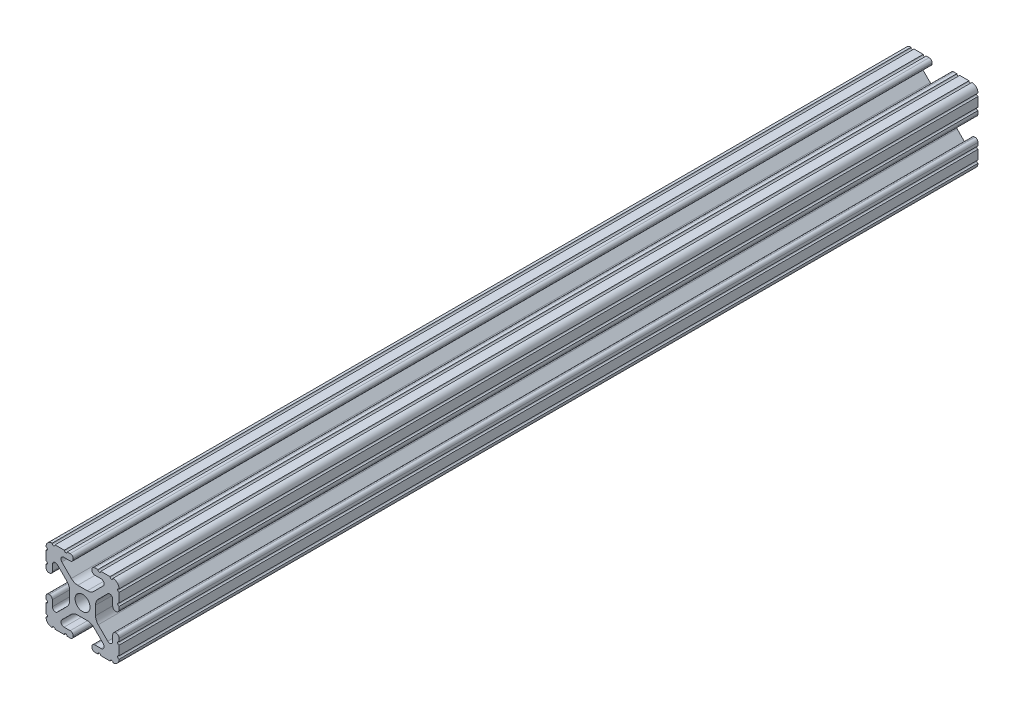
from build123d import *

# Parameters (mm, degrees)
SKETCH1_R           = 2.6035
BOSS_EXTRUDE1_DEPTH = 149.225


with BuildPart() as part:
    # Sketch1 → Boss-Extrude1 (new body, symmetric)
    with BuildSketch(Plane.XY):
        with BuildLine():
            Line((-7.179650497, -8.645192506), (-3.952270251, -5.423690499))
            ThreePointArc((-3.952270251, -5.423690499), (-2.922936451, -4.736929036), (-1.709253557, -4.4958))
            Line((-1.709253557, -4.4958), (1.709253557, -4.4958))
            ThreePointArc((1.709253557, -4.4958), (2.922936451, -4.736929036), (3.952270251, -5.423690499))
            Line((3.952270251, -5.423690499), (7.179650497, -8.645192506))
            ThreePointArc((7.179650497, -8.645192506), (7.41473083, -9.822813117), (6.416408329, -10.4902))
            Line((6.416408329, -10.4902), (4.287512407, -10.4902))
            ThreePointArc((4.287512407, -10.4902), (3.54574862, -10.79744862), (3.2385, -11.539212407))
            Line((3.2385, -11.539212407), (3.2385, -11.650987593))
            ThreePointArc((3.2385, -11.650987593), (3.54574862, -12.39275138), (4.287512407, -12.7))
            Line((4.287512407, -12.7), (5.317126718, -12.7))
            ThreePointArc((5.317126718, -12.7), (5.825126718, -12.192), (6.333126718, -12.7))
            Line((6.333126718, -12.7), (9.550443118, -12.7))
            ThreePointArc((9.550443118, -12.7), (10.058366869, -12.192000006), (10.566443095, -12.699847501))
            ThreePointArc((10.566443095, -12.699847501), (12.082537762, -12.08250727), (12.699846982, -10.566399977))
            ThreePointArc((12.699846982, -10.566399977), (12.192000006, -10.058323491), (12.7, -9.5504))
            Line((12.7, -9.5504), (12.7, -6.3330836))
            ThreePointArc((12.7, -6.3330836), (12.192, -5.8250836), (12.7, -5.3170836))
            Line((12.7, -5.3170836), (12.7, -4.287469289))
            ThreePointArc((12.7, -4.287469289), (12.39275138, -3.545705502), (11.650987593, -3.238456882))
            Line((11.650987593, -3.238456882), (11.539212407, -3.238456882))
            ThreePointArc((11.539212407, -3.238456882), (10.79744862, -3.545705502), (10.4902, -4.287469289))
            Line((10.4902, -4.287469289), (10.4902, -6.402089023))
            ThreePointArc((10.4902, -6.402089023), (9.856505071, -7.351067942), (8.737131347, -7.129408934))
            Line((8.737131347, -7.129408934), (5.441005833, -3.840816462))
            ThreePointArc((5.441005833, -3.840816462), (4.750877967, -2.809883091), (4.5085, -1.593185507))
            Line((4.5085, -1.593185507), (4.5085, 1.593185507))
            ThreePointArc((4.5085, 1.593185507), (4.750877967, 2.809883091), (5.441005833, 3.840816462))
            Line((5.441005833, 3.840816462), (8.737131347, 7.129408934))
            ThreePointArc((8.737131347, 7.129408934), (9.856505071, 7.351067942), (10.4902, 6.402089023))
            Line((10.4902, 6.402089023), (10.4902, 4.287469289))
            ThreePointArc((10.4902, 4.287469289), (10.79744862, 3.545705502), (11.539212407, 3.238456882))
            Line((11.539212407, 3.238456882), (11.650987593, 3.238456882))
            ThreePointArc((11.650987593, 3.238456882), (12.39275138, 3.545705502), (12.7, 4.287469289))
            Line((12.7, 4.287469289), (12.7, 5.3170836))
            ThreePointArc((12.7, 5.3170836), (12.192, 5.8250836), (12.7, 6.3330836))
            Line((12.7, 6.3330836), (12.7, 9.5504))
            ThreePointArc((12.7, 9.5504), (12.192000006, 10.058323491), (12.699846982, 10.566399977))
            ThreePointArc((12.699846982, 10.566399977), (12.082537762, 12.08250727), (10.566443095, 12.699847501))
            ThreePointArc((10.566443095, 12.699847501), (10.058366869, 12.192000006), (9.550443118, 12.7))
            Line((9.550443118, 12.7), (6.333126718, 12.7))
            ThreePointArc((6.333126718, 12.7), (5.825126718, 12.192), (5.317126718, 12.7))
            Line((5.317126718, 12.7), (4.287512407, 12.7))
            ThreePointArc((4.287512407, 12.7), (3.54574862, 12.39275138), (3.2385, 11.650987593))
            Line((3.2385, 11.650987593), (3.2385, 11.539212407))
            ThreePointArc((3.2385, 11.539212407), (3.54574862, 10.79744862), (4.287512407, 10.4902))
            Line((4.287512407, 10.4902), (6.476788598, 10.4902))
            ThreePointArc((6.476788598, 10.4902), (7.432222385, 9.85140422), (7.207036008, 8.724370562))
            Line((7.207036008, 8.724370562), (3.898272566, 5.423169045))
            ThreePointArc((3.898272566, 5.423169045), (2.869120213, 4.736787962), (1.655778399, 4.4958))
            Line((1.655778399, 4.4958), (-1.655778399, 4.4958))
            ThreePointArc((-1.655778399, 4.4958), (-2.869120213, 4.736787962), (-3.898272566, 5.423169045))
            Line((-3.898272566, 5.423169045), (-7.207036008, 8.724370562))
            ThreePointArc((-7.207036008, 8.724370562), (-7.432222385, 9.85140422), (-6.476788598, 10.4902))
            Line((-6.476788598, 10.4902), (-4.287512407, 10.4902))
            ThreePointArc((-4.287512407, 10.4902), (-3.54574862, 10.79744862), (-3.2385, 11.539212407))
            Line((-3.2385, 11.539212407), (-3.2385, 11.650987593))
            ThreePointArc((-3.2385, 11.650987593), (-3.54574862, 12.39275138), (-4.287512407, 12.7))
            Line((-4.287512407, 12.7), (-5.317126718, 12.7))
            ThreePointArc((-5.317126718, 12.7), (-5.825126718, 12.192), (-6.333126718, 12.7))
            Line((-6.333126718, 12.7), (-9.550443118, 12.7))
            ThreePointArc((-9.550443118, 12.7), (-10.058366869, 12.192000006), (-10.566443095, 12.699847501))
            ThreePointArc((-10.566443095, 12.699847501), (-12.082537762, 12.08250727), (-12.699846982, 10.566399977))
            ThreePointArc((-12.699846982, 10.566399977), (-12.192000006, 10.058323491), (-12.7, 9.5504))
            Line((-12.7, 9.5504), (-12.7, 6.3330836))
            ThreePointArc((-12.7, 6.3330836), (-12.192, 5.8250836), (-12.7, 5.3170836))
            Line((-12.7, 5.3170836), (-12.7, 4.287469289))
            ThreePointArc((-12.7, 4.287469289), (-12.39275138, 3.545705502), (-11.650987593, 3.238456882))
            Line((-11.650987593, 3.238456882), (-11.539212407, 3.238456882))
            ThreePointArc((-11.539212407, 3.238456882), (-10.79744862, 3.545705502), (-10.4902, 4.287469289))
            Line((-10.4902, 4.287469289), (-10.4902, 6.402089023))
            ThreePointArc((-10.4902, 6.402089023), (-9.856505071, 7.351067942), (-8.737131347, 7.129408934))
            Line((-8.737131347, 7.129408934), (-5.441005833, 3.840816462))
            ThreePointArc((-5.441005833, 3.840816462), (-4.750877967, 2.809883091), (-4.5085, 1.593185507))
            Line((-4.5085, 1.593185507), (-4.5085, -1.593185507))
            ThreePointArc((-4.5085, -1.593185507), (-4.750877967, -2.809883091), (-5.441005833, -3.840816462))
            Line((-5.441005833, -3.840816462), (-8.737131347, -7.129408934))
            ThreePointArc((-8.737131347, -7.129408934), (-9.856505071, -7.351067942), (-10.4902, -6.402089023))
            Line((-10.4902, -6.402089023), (-10.4902, -4.287469289))
            ThreePointArc((-10.4902, -4.287469289), (-10.79744862, -3.545705502), (-11.539212407, -3.238456882))
            Line((-11.539212407, -3.238456882), (-11.650987593, -3.238456882))
            ThreePointArc((-11.650987593, -3.238456882), (-12.39275138, -3.545705502), (-12.7, -4.287469289))
            Line((-12.7, -4.287469289), (-12.7, -5.3170836))
            ThreePointArc((-12.7, -5.3170836), (-12.192, -5.8250836), (-12.7, -6.3330836))
            Line((-12.7, -6.3330836), (-12.7, -9.5504))
            ThreePointArc((-12.7, -9.5504), (-12.192000006, -10.058323491), (-12.699846982, -10.566399977))
            ThreePointArc((-12.699846982, -10.566399977), (-12.082537762, -12.08250727), (-10.566443095, -12.699847501))
            ThreePointArc((-10.566443095, -12.699847501), (-10.058366869, -12.192000006), (-9.550443118, -12.7))
            Line((-9.550443118, -12.7), (-6.333126718, -12.7))
            ThreePointArc((-6.333126718, -12.7), (-5.825126718, -12.192), (-5.317126718, -12.7))
            Line((-5.317126718, -12.7), (-4.287512407, -12.7))
            ThreePointArc((-4.287512407, -12.7), (-3.54574862, -12.39275138), (-3.2385, -11.650987593))
            Line((-3.2385, -11.650987593), (-3.2385, -11.539212407))
            ThreePointArc((-3.2385, -11.539212407), (-3.54574862, -10.79744862), (-4.287512407, -10.4902))
            Line((-4.287512407, -10.4902), (-6.416408329, -10.4902))
            ThreePointArc((-6.416408329, -10.4902), (-7.41473083, -9.822813117), (-7.179650497, -8.645192506))
        make_face()
        Circle(SKETCH1_R, mode=Mode.SUBTRACT)
    extrude(amount=BOSS_EXTRUDE1_DEPTH, both=True)


solid = part.part
